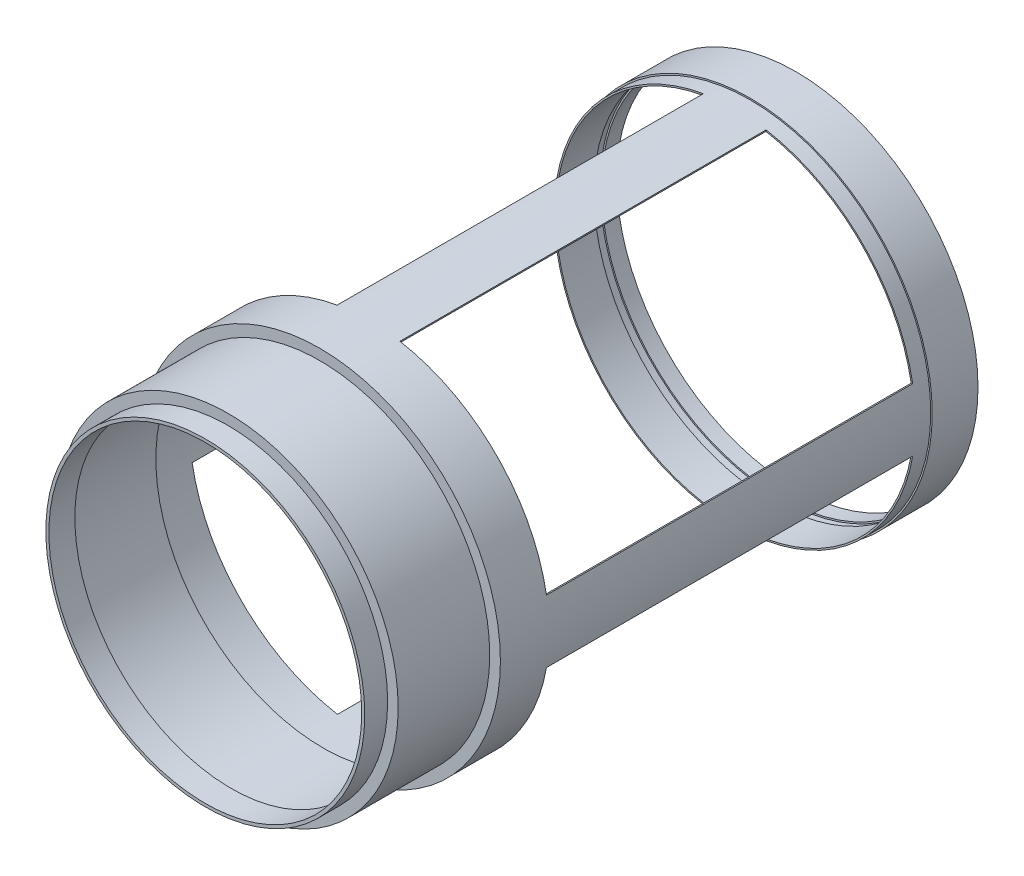
from build123d import *

# Parameters (mm, degrees)
SKETCH1_R       = 119.4
SKETCH1_R_2     = 117.4
EXTRUDE1_DEPTH  = 10
SKETCH2_R       = 119.4
SKETCH2_R_2     = 118.4
EXTRUDE2_DEPTH  = 5
SKETCH3_R       = 119.4
SKETCH3_R_2     = 117.4
EXTRUDE3_DEPTH  = 15
SKETCH4_R       = 118.4
SKETCH4_R_2     = 117.4
EXTRUDE4_DEPTH  = 10
EXTRUDE5_DEPTH  = 240
SKETCH6_R       = 118.4
SKETCH6_R_2     = 117.4
EXTRUDE6_DEPTH  = 30
SKETCH7_R       = 118.4
SKETCH7_R_2     = 109.4
EXTRUDE7_DEPTH  = 2
SKETCH8_R       = 111.4
SKETCH8_R_2     = 109.4
EXTRUDE8_DEPTH  = 60
SKETCH9_R       = 111.4
SKETCH9_R_2     = 102.5
EXTRUDE9_DEPTH  = 2
SKETCH10_R      = 104.5
SKETCH10_R_2    = 102.5
EXTRUDE10_DEPTH = 15


with BuildPart() as part:
    # Sketch1 → Extrude1 (new body)
    with BuildSketch(Plane.XY):
        Circle(SKETCH1_R)
        Circle(SKETCH1_R_2, mode=Mode.SUBTRACT)
    extrude(amount=EXTRUDE1_DEPTH)

    # Sketch2 → Extrude2 (add)
    with BuildSketch(Plane.XY.offset(10)):
        Circle(SKETCH2_R)
        Circle(SKETCH2_R_2, mode=Mode.SUBTRACT)
    extrude(amount=EXTRUDE2_DEPTH)

    # Sketch3 → Extrude3 (add)
    with BuildSketch(Plane.XY.offset(15)):
        Circle(SKETCH3_R)
        Circle(SKETCH3_R_2, mode=Mode.SUBTRACT)
    extrude(amount=EXTRUDE3_DEPTH)

    # Sketch4 → Extrude4 (add)
    with BuildSketch(Plane.XY.offset(30)):
        Circle(SKETCH4_R)
        Circle(SKETCH4_R_2, mode=Mode.SUBTRACT)
    extrude(amount=EXTRUDE4_DEPTH)

    # Sketch5 → Extrude5 (add)
    with BuildSketch(Plane.XY.offset(40)):
        with BuildLine():
            Line((20.559944, 116.601238), (20.386296, 115.61643))
            ThreePointArc((20.386296, 115.61643), (0, 117.4), (-20.386296, 115.61643))
            Line((-20.386296, 115.61643), (-20.559944, 116.601238))
            ThreePointArc((-20.559944, 116.601238), (0, 118.4), (20.559944, 116.601238))
        make_face()
        with BuildLine():
            Line((116.601238, 20.559944), (115.61643, 20.386296))
            ThreePointArc((115.61643, 20.386296), (117.4, 0), (115.61643, -20.386296))
            Line((115.61643, -20.386296), (116.601238, -20.559944))
            ThreePointArc((116.601238, -20.559944), (118.4, 0), (116.601238, 20.559944))
        make_face()
        with BuildLine():
            Line((20.559944, -116.601238), (20.386296, -115.61643))
            ThreePointArc((20.386296, -115.61643), (0, -117.4), (-20.386296, -115.61643))
            Line((-20.386296, -115.61643), (-20.559944, -116.601238))
            ThreePointArc((-20.559944, -116.601238), (0, -118.4), (20.559944, -116.601238))
        make_face()
        with BuildLine():
            Line((-115.61643, -20.386296), (-116.601238, -20.559944))
            ThreePointArc((-116.601238, -20.559944), (-118.4, 0), (-116.601238, 20.559944))
            Line((-116.601238, 20.559944), (-115.61643, 20.386296))
            ThreePointArc((-115.61643, 20.386296), (-117.4, 0), (-115.61643, -20.386296))
        make_face()
    extrude(amount=EXTRUDE5_DEPTH)

    # Sketch6 → Extrude6 (add)
    with BuildSketch(Plane.XY.offset(280)):
        Circle(SKETCH6_R)
        Circle(SKETCH6_R_2, mode=Mode.SUBTRACT)
    extrude(amount=EXTRUDE6_DEPTH)

    # Sketch7 → Extrude7 (add)
    with BuildSketch(Plane.XY.offset(310)):
        Circle(SKETCH7_R)
        Circle(SKETCH7_R_2, mode=Mode.SUBTRACT)
    extrude(amount=EXTRUDE7_DEPTH)

    # Sketch8 → Extrude8 (add)
    with BuildSketch(Plane.XY.offset(312)):
        Circle(SKETCH8_R)
        Circle(SKETCH8_R_2, mode=Mode.SUBTRACT)
    extrude(amount=EXTRUDE8_DEPTH)

    # Sketch9 → Extrude9 (add)
    with BuildSketch(Plane.XY.offset(372)):
        Circle(SKETCH9_R)
        Circle(SKETCH9_R_2, mode=Mode.SUBTRACT)
    extrude(amount=-EXTRUDE9_DEPTH)

    # Sketch10 → Extrude10 (add)
    with BuildSketch(Plane.XY.offset(372)):
        Circle(SKETCH10_R)
        Circle(SKETCH10_R_2, mode=Mode.SUBTRACT)
    extrude(amount=EXTRUDE10_DEPTH)


solid = part.part
